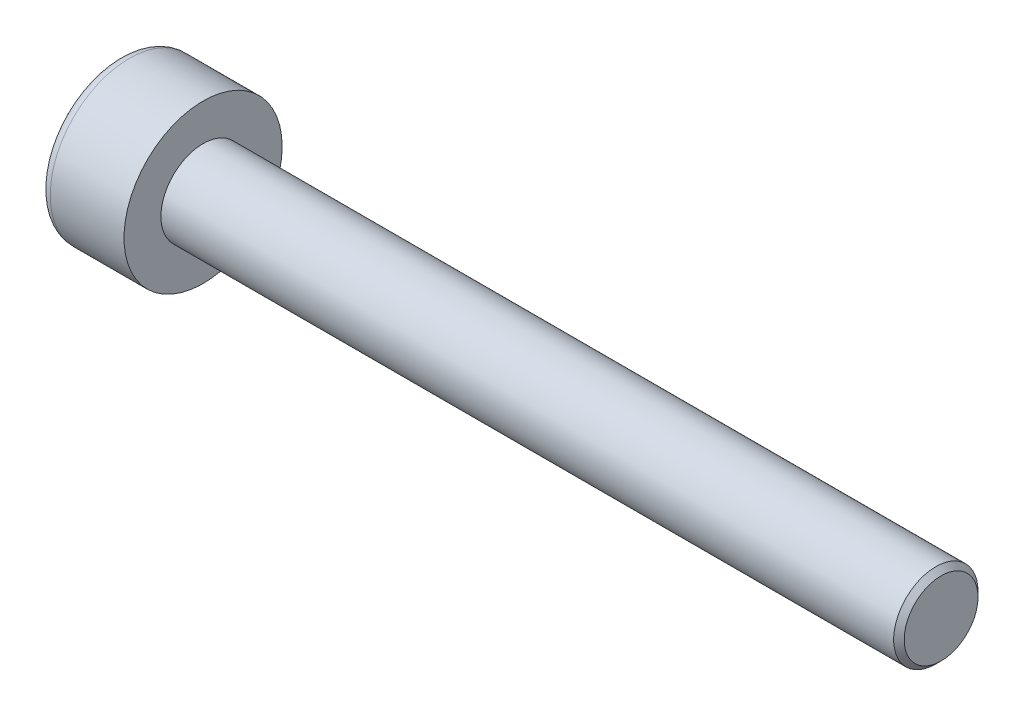
from build123d import *

# Parameters (mm, degrees)
SKETCH1_R           = 1.5
BASEHEAD_DEPTH      = 1.6
SKETCH2_R           = 0.8
BASEBODY_DEPTH      = 14
HEXAGONSOCKET_DEPTH = 0.7
TOPFILLET_R         = 0.2
CHAMFER1_SIZE       = 0.1


with BuildPart() as part:
    # Sketch1 → BaseHead (new body)
    with BuildSketch(Plane(origin=(0, 0, 0), x_dir=(0, 0, -1), z_dir=(1, 0, 0))):
        Circle(SKETCH1_R)
    extrude(amount=BASEHEAD_DEPTH)

    # Sketch2 → BaseBody (add)
    with BuildSketch(Plane(origin=(1.6, 0, 0), x_dir=(0, 0, -1), z_dir=(1, 0, 0))):
        Circle(SKETCH2_R)
    extrude(amount=BASEBODY_DEPTH)

    # Sketch3 → HexagonSocket (cut)
    with BuildSketch(Plane(origin=(0, 0, 0), x_dir=(0, 0, -1), z_dir=(1, 0, 0))):
        Polygon((0.866025404, 0), (0.433012702, 0.75), (-0.433012702, 0.75), (-0.866025404, 0), (-0.433012702, -0.75), (0.433012702, -0.75), align=None)
    extrude(amount=HEXAGONSOCKET_DEPTH, mode=Mode.SUBTRACT)

    # Sketch4 → Cut-Revolve1 (revolve, cut)
    with BuildSketch(Plane(origin=(-4.19613823, 0.75, 0), x_dir=(-1, 0, 0), z_dir=(0, 0, 1))):
        Polygon((-4.89613823, 1.5), (-5.329150931, 0.75), (-4.89613823, 0.75), align=None)
    revolve(axis=Axis((0.838992387, 0, 0), (-1, 0, 0)), mode=Mode.SUBTRACT)

    # TopFillet
    topfillet_edges = [part.edges().sort_by_distance(p)[0] for p in [
        (0, 0, 1.5),
    ]]
    fillet(topfillet_edges, radius=TOPFILLET_R)

    # Chamfer1
    chamfer1_edges = [part.edges().sort_by_distance(p)[0] for p in [
        (15.6, 0, 0.8),
    ]]
    chamfer(chamfer1_edges, length=CHAMFER1_SIZE)


solid = part.part
